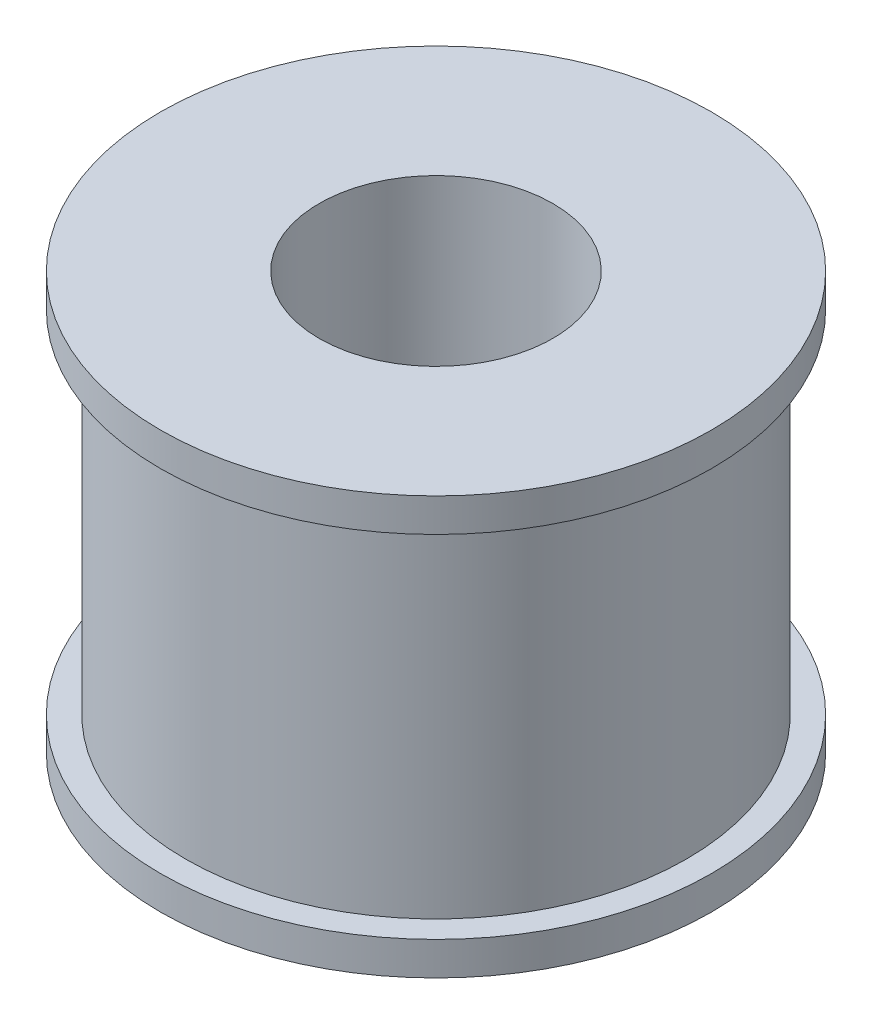
from build123d import *

# Parameters (mm, degrees)
CROQUIS1_R              = 15
CROQUIS1_R_2            = 3
SALIENTE_EXTRUIR1_DEPTH = 25
CROQUIS2_R              = 16.5
CROQUIS2_R_2            = 3
SALIENTE_EXTRUIR2_DEPTH = 2
CROQUIS3_R              = 16.5
CROQUIS3_R_2            = 3
SALIENTE_EXTRUIR3_DEPTH = 2
CORTAR_EXTRUIR1_REACH   = 18.5
CROQUIS4_R              = 1.625
CROQUIS5_R              = 7
CORTAR_EXTRUIR2_DEPTH   = 16


with BuildPart() as part:
    # Croquis1 → Saliente-Extruir1 (new body)
    with BuildSketch(Plane(origin=(0, 0, 0), x_dir=(1, 0, 0), z_dir=(0, 1, 0))):
        Circle(CROQUIS1_R)
        Circle(CROQUIS1_R_2, mode=Mode.SUBTRACT)
    extrude(amount=SALIENTE_EXTRUIR1_DEPTH)

    # Croquis2 → Saliente-Extruir2 (add)
    with BuildSketch(Plane.XZ):
        Circle(CROQUIS2_R)
        Circle(CROQUIS2_R_2, mode=Mode.SUBTRACT)
    extrude(amount=-SALIENTE_EXTRUIR2_DEPTH)

    # Croquis3 → Saliente-Extruir3 (add)
    with BuildSketch(Plane(origin=(0, 25, 0), x_dir=(1, 0, 0), z_dir=(0, 1, 0))):
        Circle(CROQUIS3_R)
        Circle(CROQUIS3_R_2, mode=Mode.SUBTRACT)
    extrude(amount=-SALIENTE_EXTRUIR3_DEPTH)

    # Croquis4 → Cortar-Extruir1 (cut, up to next)
    with BuildSketch(Plane.XY, mode=Mode.PRIVATE) as cortar_extruir1_sk1:
        with Locations((0, 5)):
            Circle(CROQUIS4_R)
    cortar_extruir1_tool1 = extrude(cortar_extruir1_sk1.sketch, amount=-CORTAR_EXTRUIR1_REACH, mode=Mode.PRIVATE) & part.part
    add(cortar_extruir1_tool1.solids().sort_by_distance((0, 5, 0))[0], mode=Mode.SUBTRACT)

    # Croquis5 → Cortar-Extruir2 (cut)
    with BuildSketch(Plane(origin=(0, 25, 0), x_dir=(1, 0, 0), z_dir=(0, 1, 0))):
        Circle(CROQUIS5_R)
    extrude(amount=-CORTAR_EXTRUIR2_DEPTH, mode=Mode.SUBTRACT)


solid = part.part
